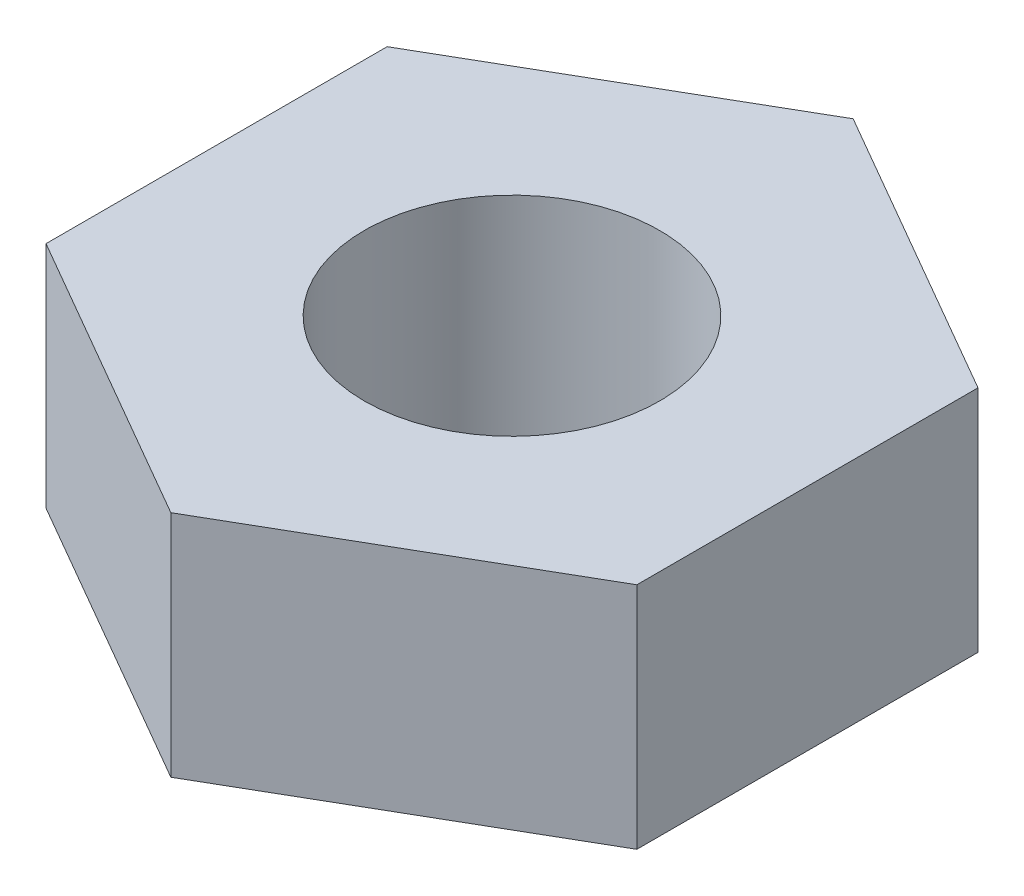
from build123d import *

# Parameters (mm, degrees)
SKETCH1_R           = 1.225
BOSS_EXTRUDE1_DEPTH = 1.9


with BuildPart() as part:
    # Sketch1 → Boss-Extrude1 (new body)
    with BuildSketch(Plane(origin=(0, 0, 0), x_dir=(1, 0, 0), z_dir=(0, 1, 0))):
        Polygon((0, -2.829016319), (2.45, -1.41450816), (2.45, 1.41450816), (0, 2.829016319), (-2.45, 1.41450816), (-2.45, -1.41450816), align=None)
        Circle(SKETCH1_R, mode=Mode.SUBTRACT)
    extrude(amount=BOSS_EXTRUDE1_DEPTH)


solid = part.part
